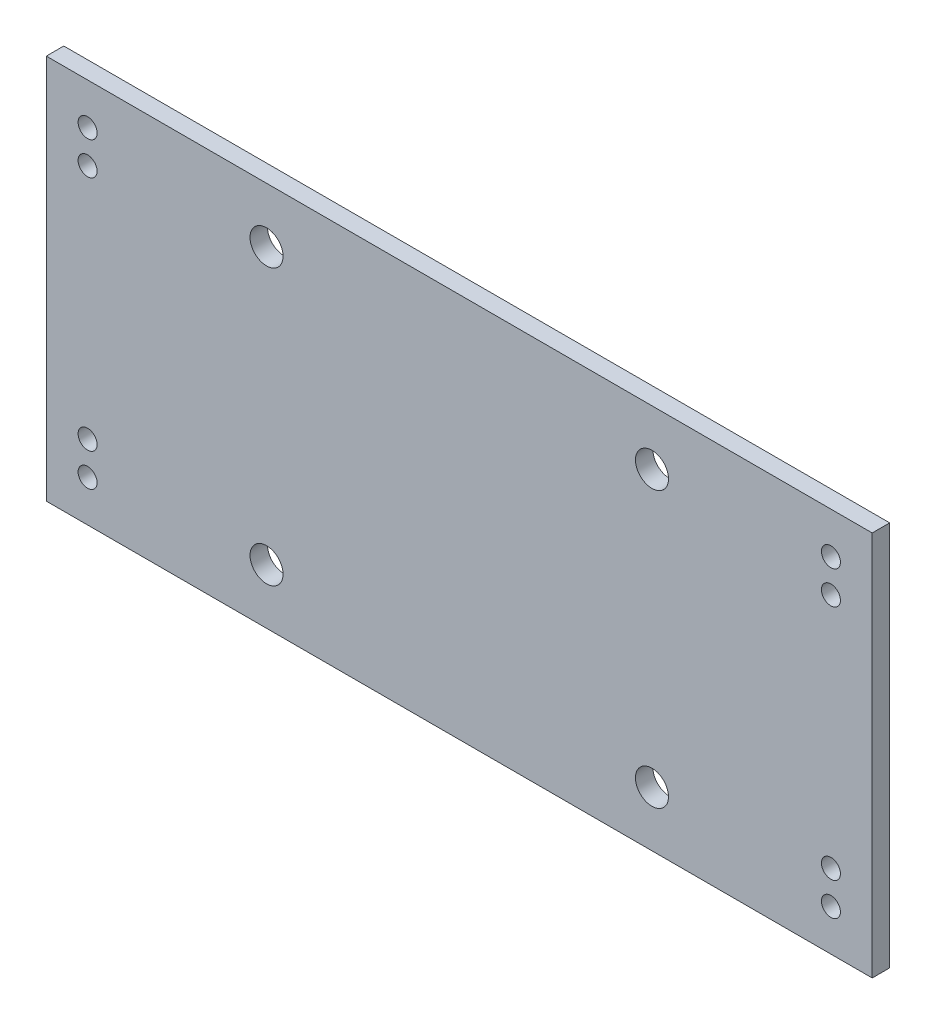
from build123d import *

# Parameters (mm, degrees)
SKETCH1_W           = 150
SKETCH1_H           = 70
SKETCH1_R           = 1.725
SKETCH1_R_2         = 3
BOSS_EXTRUDE1_DEPTH = 3.175


with BuildPart() as part:
    # Sketch1 → Boss-Extrude1 (new body)
    with BuildSketch(Plane.XY):
        with Locations((75, -35)):
            Rectangle(SKETCH1_W, SKETCH1_H)
        with Locations((7.5, -7.5)):
            Circle(SKETCH1_R, mode=Mode.SUBTRACT)
        with Locations((142.5, -7.5)):
            Circle(SKETCH1_R, mode=Mode.SUBTRACT)
        with Locations((142.5, -62.5)):
            Circle(SKETCH1_R, mode=Mode.SUBTRACT)
        with Locations((7.5, -62.5)):
            Circle(SKETCH1_R, mode=Mode.SUBTRACT)
        with Locations((7.5, -13.5)):
            Circle(SKETCH1_R, mode=Mode.SUBTRACT)
        with Locations((142.5, -13.5)):
            Circle(SKETCH1_R, mode=Mode.SUBTRACT)
        with Locations((142.5, -56.5)):
            Circle(SKETCH1_R, mode=Mode.SUBTRACT)
        with Locations((7.5, -56.5)):
            Circle(SKETCH1_R, mode=Mode.SUBTRACT)
        with Locations((40, -10)):
            Circle(SKETCH1_R_2, mode=Mode.SUBTRACT)
        with Locations((40, -60)):
            Circle(SKETCH1_R_2, mode=Mode.SUBTRACT)
        with Locations((110, -10)):
            Circle(SKETCH1_R_2, mode=Mode.SUBTRACT)
        with Locations((110, -60)):
            Circle(SKETCH1_R_2, mode=Mode.SUBTRACT)
    extrude(amount=BOSS_EXTRUDE1_DEPTH)


solid = part.part
